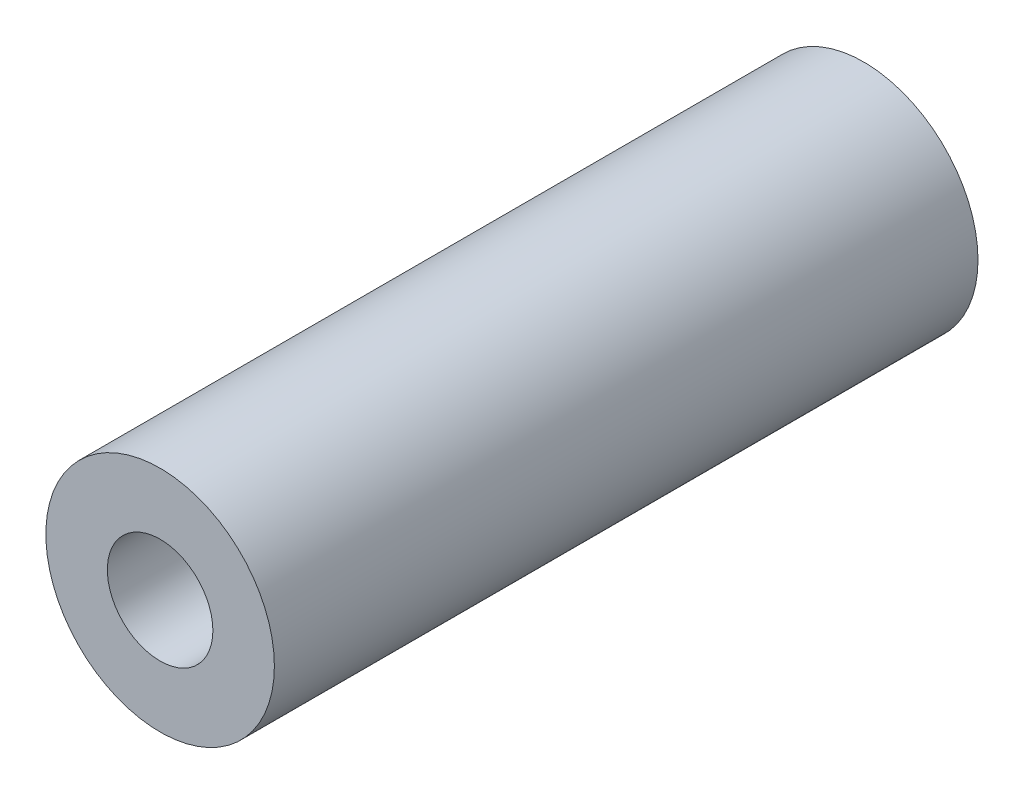
from build123d import *

# Parameters (mm, degrees)
SKETCH1_R           = 10.3124
SKETCH1_R_2         = 4.7625
BOSS_EXTRUDE1_DEPTH = 63.5


with BuildPart() as part:
    # Sketch1 → Boss-Extrude1 (new body)
    with BuildSketch(Plane.XY):
        Circle(SKETCH1_R)
        Circle(SKETCH1_R_2, mode=Mode.SUBTRACT)
    extrude(amount=BOSS_EXTRUDE1_DEPTH)


solid = part.part
